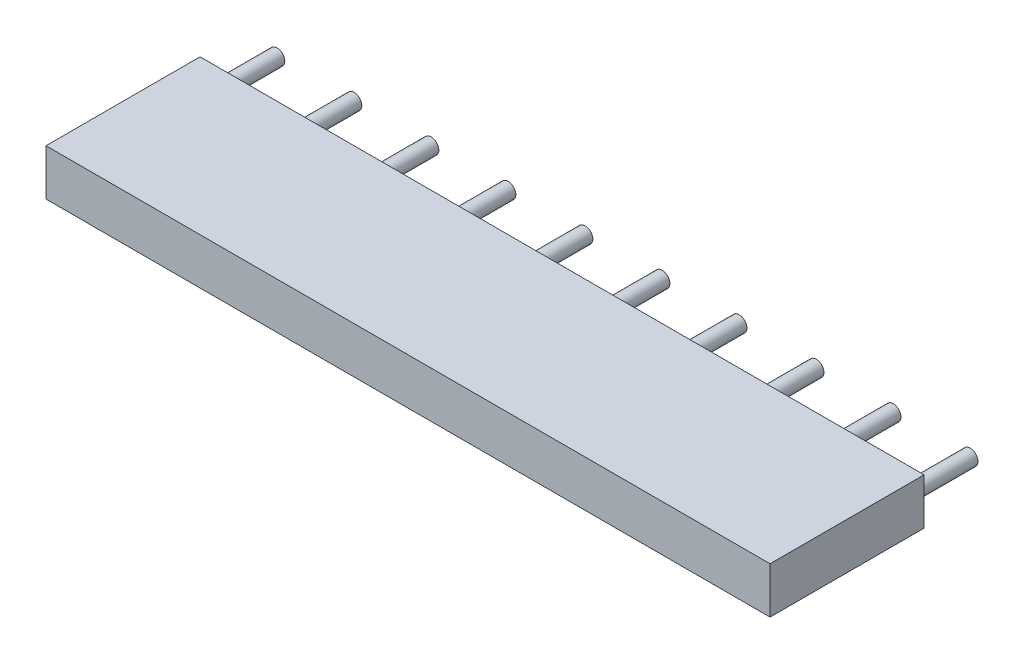
from build123d import *

# Parameters (mm, degrees)
SKETCH1_W               = 23.5
SKETCH1_H               = 1.5
COMPONENT_OUTLINE_DEPTH = 5
SKETCH2_R               = 0.25
EXTRUDE_1_DEPTH         = 2
SKETCH3_R               = 0.25
EXTRUDE_2_DEPTH         = 2
SKETCH4_R               = 0.25
EXTRUDE_3_DEPTH         = 2
SKETCH5_R               = 0.25
EXTRUDE_4_DEPTH         = 2
SKETCH6_R               = 0.25
EXTRUDE_5_DEPTH         = 2
SKETCH7_R               = 0.25
EXTRUDE_6_DEPTH         = 2
SKETCH8_R               = 0.25
EXTRUDE_7_DEPTH         = 2
SKETCH9_R               = 0.25
EXTRUDE_8_DEPTH         = 2
SKETCH10_R              = 0.25
EXTRUDE_9_DEPTH         = 2
SKETCH11_R              = 0.25
EXTRUDE_10_DEPTH        = 2


with BuildPart() as part:
    # Sketch1 → Component_Outline (new body)
    with BuildSketch(Plane.XY):
        with Locations((11.25, 0)):
            Rectangle(SKETCH1_W, SKETCH1_H)
    extrude(amount=COMPONENT_OUTLINE_DEPTH)


with BuildPart() as body_2:
    # Sketch2 → Extrude 1 (new body)
    with BuildSketch(Plane.XY):
        Circle(SKETCH2_R)
    extrude(amount=-EXTRUDE_1_DEPTH)


with BuildPart() as body_3:
    # Sketch3 → Extrude 2 (new body)
    with BuildSketch(Plane.XY):
        with Locations((2.5, 0)):
            Circle(SKETCH3_R)
    extrude(amount=-EXTRUDE_2_DEPTH)


with BuildPart() as body_4:
    # Sketch4 → Extrude 3 (new body)
    with BuildSketch(Plane.XY):
        with Locations((5, 0)):
            Circle(SKETCH4_R)
    extrude(amount=-EXTRUDE_3_DEPTH)


with BuildPart() as body_5:
    # Sketch5 → Extrude 4 (new body)
    with BuildSketch(Plane.XY):
        with Locations((7.5, 0)):
            Circle(SKETCH5_R)
    extrude(amount=-EXTRUDE_4_DEPTH)


with BuildPart() as body_6:
    # Sketch6 → Extrude 5 (new body)
    with BuildSketch(Plane.XY):
        with Locations((10, 0)):
            Circle(SKETCH6_R)
    extrude(amount=-EXTRUDE_5_DEPTH)


with BuildPart() as body_7:
    # Sketch7 → Extrude 6 (new body)
    with BuildSketch(Plane.XY):
        with Locations((12.5, 0)):
            Circle(SKETCH7_R)
    extrude(amount=-EXTRUDE_6_DEPTH)


with BuildPart() as body_8:
    # Sketch8 → Extrude 7 (new body)
    with BuildSketch(Plane.XY):
        with Locations((15, 0)):
            Circle(SKETCH8_R)
    extrude(amount=-EXTRUDE_7_DEPTH)


with BuildPart() as body_9:
    # Sketch9 → Extrude 8 (new body)
    with BuildSketch(Plane.XY):
        with Locations((17.5, 0)):
            Circle(SKETCH9_R)
    extrude(amount=-EXTRUDE_8_DEPTH)


with BuildPart() as body_10:
    # Sketch10 → Extrude 9 (new body)
    with BuildSketch(Plane.XY):
        with Locations((20, 0)):
            Circle(SKETCH10_R)
    extrude(amount=-EXTRUDE_9_DEPTH)


with BuildPart() as body_11:
    # Sketch11 → Extrude 10 (new body)
    with BuildSketch(Plane.XY):
        with Locations((22.5, 0)):
            Circle(SKETCH11_R)
    extrude(amount=-EXTRUDE_10_DEPTH)


solid = Compound([part.part, body_2.part, body_3.part, body_4.part, body_5.part, body_6.part, body_7.part, body_8.part, body_9.part, body_10.part, body_11.part])
